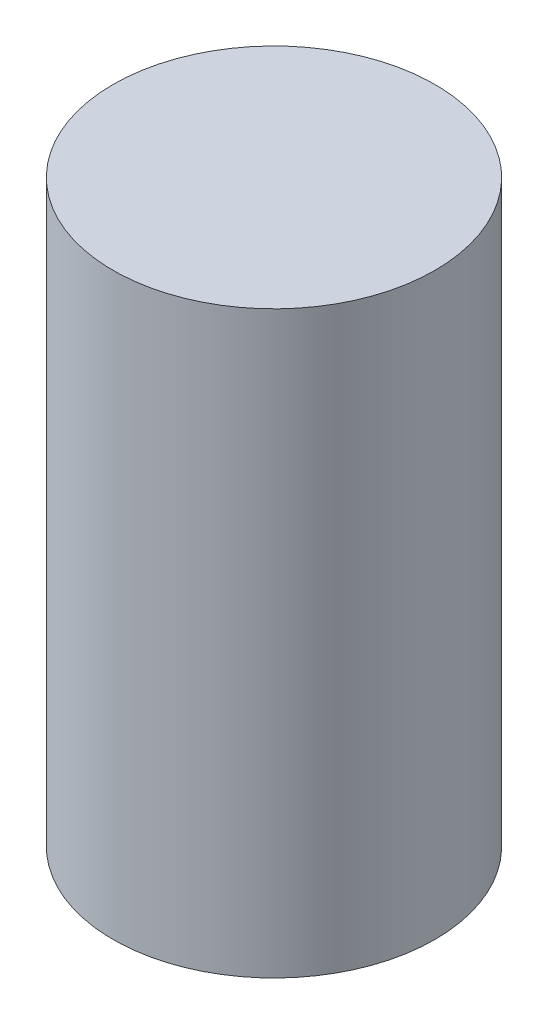
from build123d import *

# Parameters (mm, degrees)
SKETCH1_W = 17.5
SKETCH1_H = 63


with BuildPart() as part:
    # Sketch1 → Revolve1 (revolve)
    with BuildSketch(Plane.XY):
        with Locations((-8.75, 0)):
            Rectangle(SKETCH1_W, SKETCH1_H)
    revolve(axis=Axis((0, 31.5, 0), (0, 1, 0)))


solid = part.part
